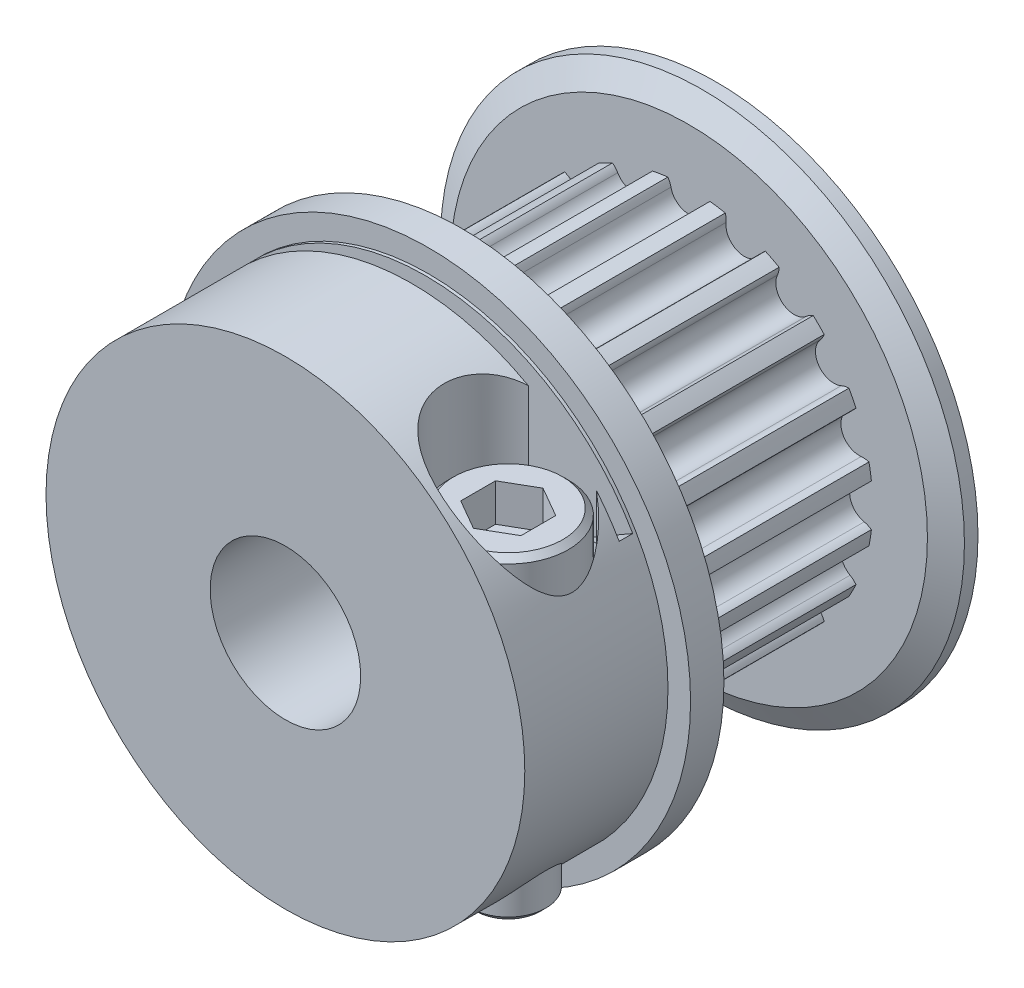
from build123d import *

# Parameters (mm, degrees)
SKETCH1_W               = 6
SKETCH1_H               = 5.45
SKETCH2_W               = 0.45
SKETCH2_H               = 5.45
CUT_REVOLVE1_ANGLE      = 180
CUT_EXTRUDE1_DEPTH      = 1.25
BOSS_EXTRUDE1_START     = 7.4
SKETCH7_R               = 6.1
SKETCH7_R_2             = 2.5
BOSS_EXTRUDE1_DEPTH     = 7.4
CUT_EXTRUDE2_START      = -7.4
CUT_EXTRUDE2_DEPTH      = 7.4
CIRPATTERN1_COUNT       = 20
SKETCH10_R              = 5.49
SKETCH10_R_2            = 2.5
BOSS_EXTRUDE2_DEPTH     = 0.45
SKETCH11_R              = 4.3254
SKETCH11_R_2            = 4.2746
CUT_EXTRUDE_THIN1_DEPTH = 0.0508


with BuildPart() as part:
    # Sketch1 → Revolve1 (revolve)
    with BuildSketch(Plane(origin=(0, 0, 0), x_dir=(0, 0, -1), z_dir=(1, 0, 0))):
        with Locations((-3, 5.225)):
            Rectangle(SKETCH1_W, SKETCH1_H)
    revolve(axis=Axis((0, 0, 6.3), (0, 0, -1)))

    # Sketch2 → Cut-Revolve1 (revolve, cut)
    with BuildSketch(Plane(origin=(0, 0, 0), x_dir=(0, 0, -1), z_dir=(-0.49999999999999994, 0.8660254037844387, 0))):
        with Locations((-1.575, 5.225)):
            Rectangle(SKETCH2_W, SKETCH2_H)
    revolve(axis=Axis((0, 0, 1.8225), (0, 0, -1)), revolution_arc=CUT_REVOLVE1_ANGLE, mode=Mode.SUBTRACT)

    # Sketch4 → Cut-Revolve2 (revolve, cut)
    with BuildSketch(Plane.XY.offset(3.6)):
        Polygon((2.875, 7.411941379), (2.875, 2.385), (3.7375, 2.385), (3.7375, -7.01666543), (5, -7.01666543), (5, 7.411941379), align=None)
    revolve(axis=Axis((5, -7.73809577, 3.6), (0, 1, 0)), mode=Mode.SUBTRACT)

    # Sketch5 → Revolve2 (revolve)
    with BuildSketch(Plane(origin=(5, 0, 3.6), x_dir=(1, 0, 0), z_dir=(0, 0, 1))):
        Polygon((2, 4.6945), (2, 2.385), (1.25, 2.385), (1.25, -5.990317098), (1.0595, -6.180817098), (0, -6.180817098), (0, 4.885), (1.8095, 4.885), align=None)
    revolve(axis=Axis((5, -6.734107953, 3.6), (0, 1, 0)))

    # Sketch6 → Cut-Extrude1 (cut)
    with BuildSketch(Plane(origin=(0, 4.885, 0), x_dir=(-1, 0, 0), z_dir=(0, 1, 0))):
        Polygon((-5, 2.445299462), (-4, 3.022649731), (-4, 4.177350269), (-5, 4.754700538), (-6, 4.177350269), (-6, 3.022649731), align=None)
    extrude(amount=-CUT_EXTRUDE1_DEPTH, mode=Mode.SUBTRACT)

    # Sketch7 → Boss-Extrude1 (add)
    with BuildSketch(Plane(origin=(0, 0, 0), x_dir=(-1, 0, 0), z_dir=(0, 0, -1)).offset(BOSS_EXTRUDE1_START)):
        Circle(SKETCH7_R)
        Circle(SKETCH7_R_2, mode=Mode.SUBTRACT)
    extrude(amount=-BOSS_EXTRUDE1_DEPTH)

    # Sketch8 → Cut-Extrude2 (cut)
    with BuildSketch(Plane(origin=(0, 0, 0), x_dir=(0.9510565162951536, -0.30901699437494745, 0), z_dir=(0, 0, 1)).offset(CUT_EXTRUDE2_START)):
        with BuildLine():
            ThreePointArc((-0.596224085, 5.8206), (0, 5.338), (0.596224085, 5.8206))
            ThreePointArc((0.596224085, 5.8206), (0.63606119, 5.945322789), (0.699721013, 6.059735184))
            ThreePointArc((0.699721013, 6.059735184), (0, 6.1), (-0.699721013, 6.059735184))
            ThreePointArc((-0.699721013, 6.059735184), (-0.63606119, 5.945322789), (-0.596224085, 5.8206))
        make_face()
    cut_extrude2 = extrude(amount=CUT_EXTRUDE2_DEPTH, mode=Mode.SUBTRACT)

    # CirPattern1: Cut-Extrude2 ×20 about axis
    cirpattern1_axis = Axis((0, 0, -80.9), (0, 0, 1))
    for i in range(1, CIRPATTERN1_COUNT):
        add(cut_extrude2.rotate(cirpattern1_axis, i * 360 / CIRPATTERN1_COUNT), mode=Mode.SUBTRACT)

    # Sketch9 → Revolve3 (revolve)
    with BuildSketch(Plane(origin=(0, 0, 0), x_dir=(0, 0, -1), z_dir=(1, 0, 0))):
        Polygon((7.4, 2.5), (7.4, 7.920577137), (7.85, 8.7), (8.3, 8.7), (7.85, 7.920577137), (7.85, 2.5), align=None)
    revolve(axis=Axis((0, 0, 0.415), (0, 0, -1)))

    # Sketch10 → Boss-Extrude2 (add)
    with BuildSketch(Plane(origin=(0, 0, -7.85), x_dir=(-1, 0, 0), z_dir=(0, 0, -1))):
        Circle(SKETCH10_R)
        Circle(SKETCH10_R_2, mode=Mode.SUBTRACT)
    extrude(amount=BOSS_EXTRUDE2_DEPTH)

    # Sketch11 → Cut-Extrude-Thin1 (cut)
    with BuildSketch(Plane(origin=(0, 0, -8.3), x_dir=(-1, 0, 0), z_dir=(0, 0, -1))):
        Circle(SKETCH11_R)
        Circle(SKETCH11_R_2, mode=Mode.SUBTRACT)
    extrude(amount=-CUT_EXTRUDE_THIN1_DEPTH, mode=Mode.SUBTRACT)

    # Sketch12 → Revolve4 (revolve)
    with BuildSketch(Plane(origin=(0, 0, 0), x_dir=(0, 0, -1), z_dir=(1, 0, 0))):
        Polygon((0, 2.5), (0, 7.920577137), (-0.13743328, 8.7), (-1.245, 8.7), (-1.245, 2.5), align=None)
    revolve(axis=Axis((0, 0, 1.67725), (0, 0, -1)))


solid = part.part
